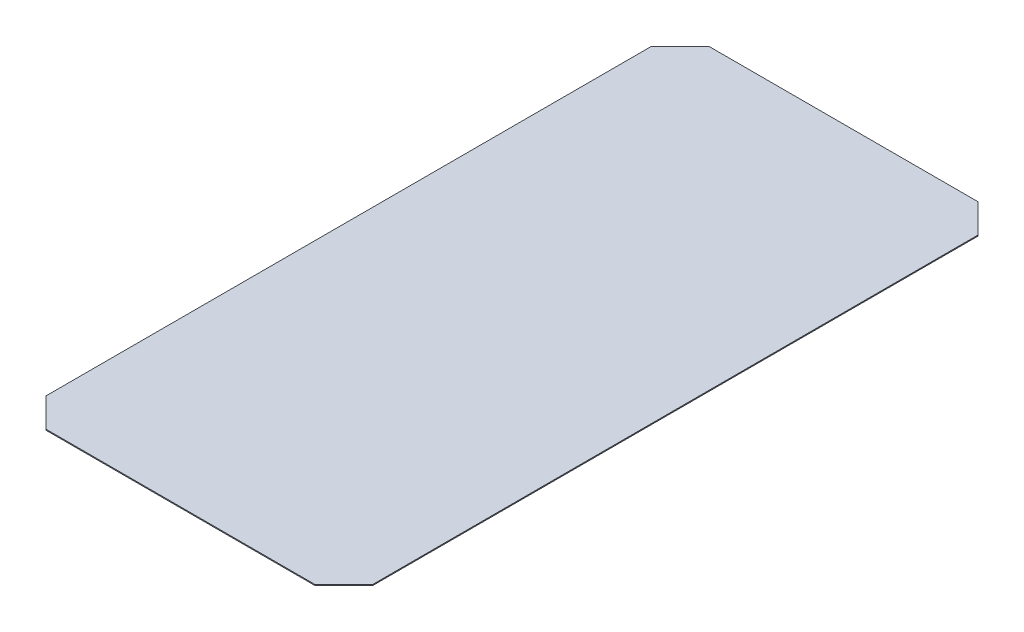
from build123d import *

# Parameters (mm, degrees)
SKETCH1_W           = 48.2
SKETCH1_H           = 80
BOSS_EXTRUDE1_DEPTH = 0.1
CUT_EXTRUDE1_DEPTH  = 47.699250529
CHAMFER1_SIZE       = 3


with BuildPart() as part:
    # Sketch1 → Boss-Extrude1 (new body)
    with BuildSketch(Plane(origin=(0, 0, 0), x_dir=(1, 0, 0), z_dir=(0, 1, 0))):
        Rectangle(SKETCH1_W, SKETCH1_H)
    extrude(amount=BOSS_EXTRUDE1_DEPTH)

    # Sketch2 → Cut-Extrude1 (cut, through all)
    with BuildSketch(Plane(origin=(0, 0.1, 0), x_dir=(1, 0, 0), z_dir=(0, 1, 0))):
        Polygon((9.9, 40), (24.1, 40), (24.1, -40), (-24.1, -40), (-24.1, -29), (9.9, -29), align=None)
    extrude(amount=-CUT_EXTRUDE1_DEPTH, mode=Mode.SUBTRACT)

    # Chamfer1
    chamfer1_edges = [part.edges().sort_by_distance(p)[0] for p in [
        (9.9, 0.05, -40),
        (-24.1, 0.05, -40),
        (9.9, 0.05, 29),
        (-24.1, 0.05, 29),
    ]]
    chamfer(chamfer1_edges, length=CHAMFER1_SIZE)


solid = part.part
